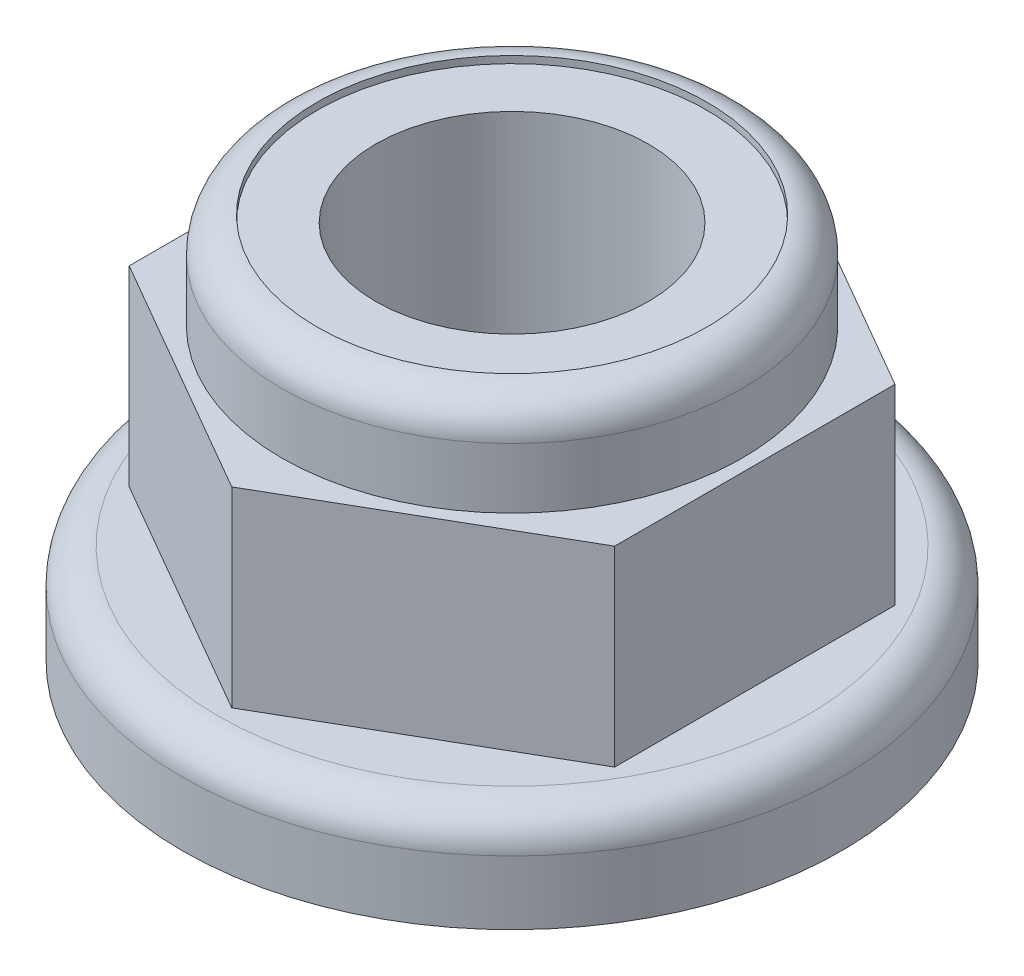
from build123d import *

# Parameters (mm, degrees)
SKETCH1_R           = 4.65
BOSS_EXTRUDE1_DEPTH = 1.4
BOSS_EXTRUDE2_DEPTH = 2.7
SKETCH3_R           = 3.25
BOSS_EXTRUDE3_DEPTH = 1.35
FILLET1_R           = 0.5
CUT_EXTRUDE1_REACH  = 7.45
SKETCH7_R           = 1.925
SKETCH8_R           = 2.75
SKETCH8_R_2         = 1.925
CUT_EXTRUDE2_DEPTH  = 0.1


with BuildPart() as part:
    # Sketch1 → Boss-Extrude1 (new body)
    with BuildSketch(Plane(origin=(0, 0, 0), x_dir=(1, 0, 0), z_dir=(0, 1, 0))):
        Circle(SKETCH1_R)
    extrude(amount=BOSS_EXTRUDE1_DEPTH)

    # Sketch2 → Boss-Extrude2 (add)
    with BuildSketch(Plane(origin=(0, 1.4, 0), x_dir=(1, 0, 0), z_dir=(0, 1, 0))):
        Polygon((0, -3.954849344), (3.425, -1.977424672), (3.425, 1.977424672), (0, 3.954849344), (-3.425, 1.977424672), (-3.425, -1.977424672), align=None)
    extrude(amount=BOSS_EXTRUDE2_DEPTH)

    # Sketch3 → Boss-Extrude3 (add)
    with BuildSketch(Plane(origin=(0, 4.1, 0), x_dir=(1, 0, 0), z_dir=(0, 1, 0))):
        Circle(SKETCH3_R)
    extrude(amount=BOSS_EXTRUDE3_DEPTH)

    # Fillet1
    fillet1_edges = [part.edges().sort_by_distance(p)[0] for p in [
        (-3.25, 5.45, 0),
        (-4.65, 1.4, 0),
    ]]
    fillet(fillet1_edges, radius=FILLET1_R)

    # Sketch7 → Cut-Extrude1 (cut, up to next)
    with BuildSketch(Plane(origin=(0, 5.45, 0), x_dir=(1, 0, 0), z_dir=(0, 1, 0)), mode=Mode.PRIVATE) as cut_extrude1_sk1:
        Circle(SKETCH7_R)
    cut_extrude1_tool1 = extrude(cut_extrude1_sk1.sketch, amount=-CUT_EXTRUDE1_REACH, mode=Mode.PRIVATE) & part.part
    add(cut_extrude1_tool1.solids().sort_by_distance((0, 5.45, 0))[0], mode=Mode.SUBTRACT)

    # Sketch8 → Cut-Extrude2 (cut)
    with BuildSketch(Plane(origin=(0, 5.45, 0), x_dir=(1, 0, 0), z_dir=(0, 1, 0))):
        Circle(SKETCH8_R)
        Circle(SKETCH8_R_2, mode=Mode.SUBTRACT)
    extrude(amount=-CUT_EXTRUDE2_DEPTH, mode=Mode.SUBTRACT)


solid = part.part
